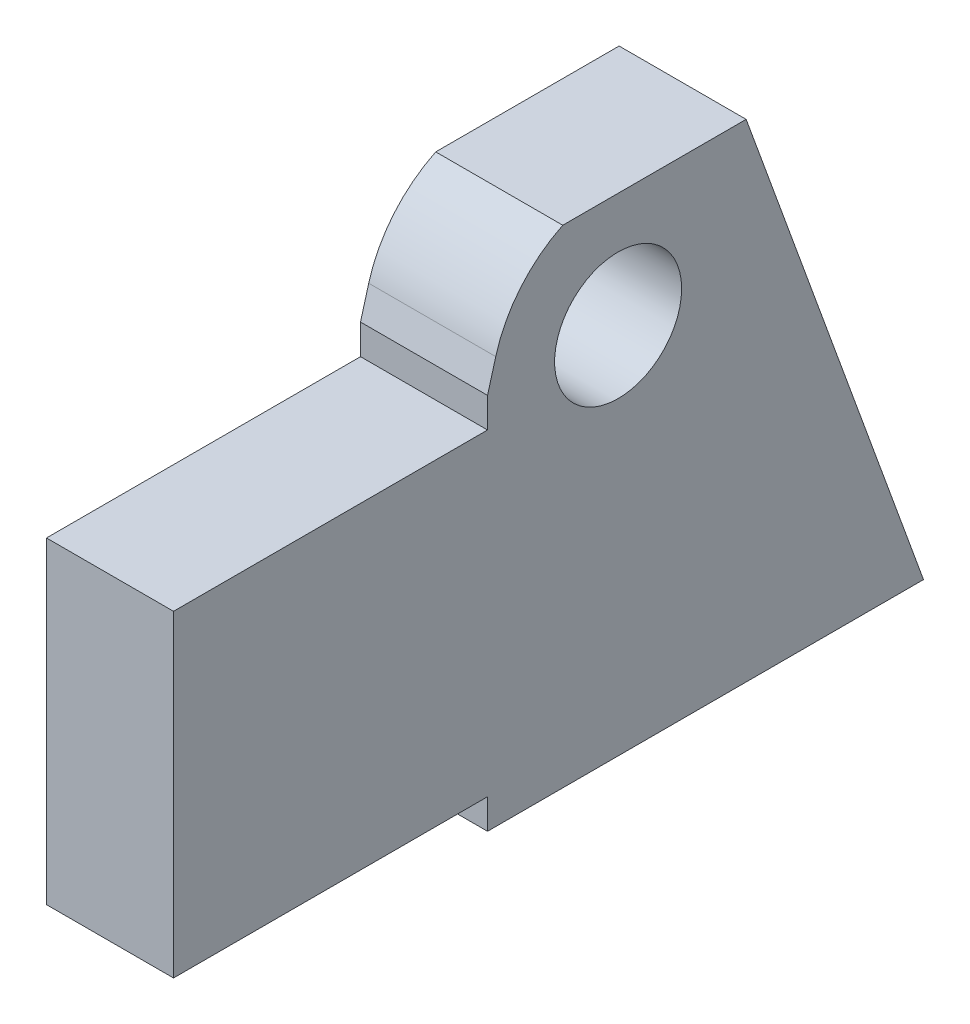
from build123d import *

# Parameters (mm, degrees)
BOSS_EXTRUDE1_DEPTH = 6.35
BOSS_EXTRUDE2_DEPTH = 12.7
SKETCH5_R           = 6.35
CUT_EXTRUDE2_DEPTH  = 13.7


with BuildPart() as part:
    # Sketch2 → Boss-Extrude1 (new body, symmetric)
    with BuildSketch(Plane(origin=(0, 0, 0), x_dir=(0, 0, -1), z_dir=(1, 0, 0))):
        Polygon((0, 31.75), (0, 0), (31.3944, 0), (31.3944, -2.9972), (74.9808, -2.9972), (61.24296189, 34.7472), (31.3944, 34.7472), (31.3944, 31.75), align=None)
    extrude(amount=BOSS_EXTRUDE1_DEPTH, both=True)

    # Sketch4 → Boss-Extrude2 (add, through all)
    with BuildSketch(Plane(origin=(6.35, 0, 0), x_dir=(0, 0, -1), z_dir=(1, 0, 0))):
        with BuildLine():
            Line((57.141767732, 34.7472), (61.24296189, 34.7472))
            Line((61.24296189, 34.7472), (57.249189303, 45.72))
            Line((57.249189303, 45.72), (38.914198342, 45.72))
            ThreePointArc((38.914198342, 45.72), (34.700855885, 42.429053325), (32.215182454, 37.695765645))
            Line((32.215182454, 37.695765645), (31.3944, 34.7472))
            Line((31.3944, 34.7472), (31.758232268, 34.7472))
            ThreePointArc((31.758232268, 34.7472), (44.45, 21.59), (57.141767732, 34.7472))
        make_face()
    extrude(amount=-BOSS_EXTRUDE2_DEPTH)

    # Sketch5 → Cut-Extrude2 (cut, through all)
    with BuildSketch(Plane(origin=(6.35, 0, 0), x_dir=(0, 0, -1), z_dir=(1, 0, 0))):
        with Locations((44.45, 34.29)):
            Circle(SKETCH5_R)
    extrude(amount=-CUT_EXTRUDE2_DEPTH, mode=Mode.SUBTRACT)


solid = part.part
